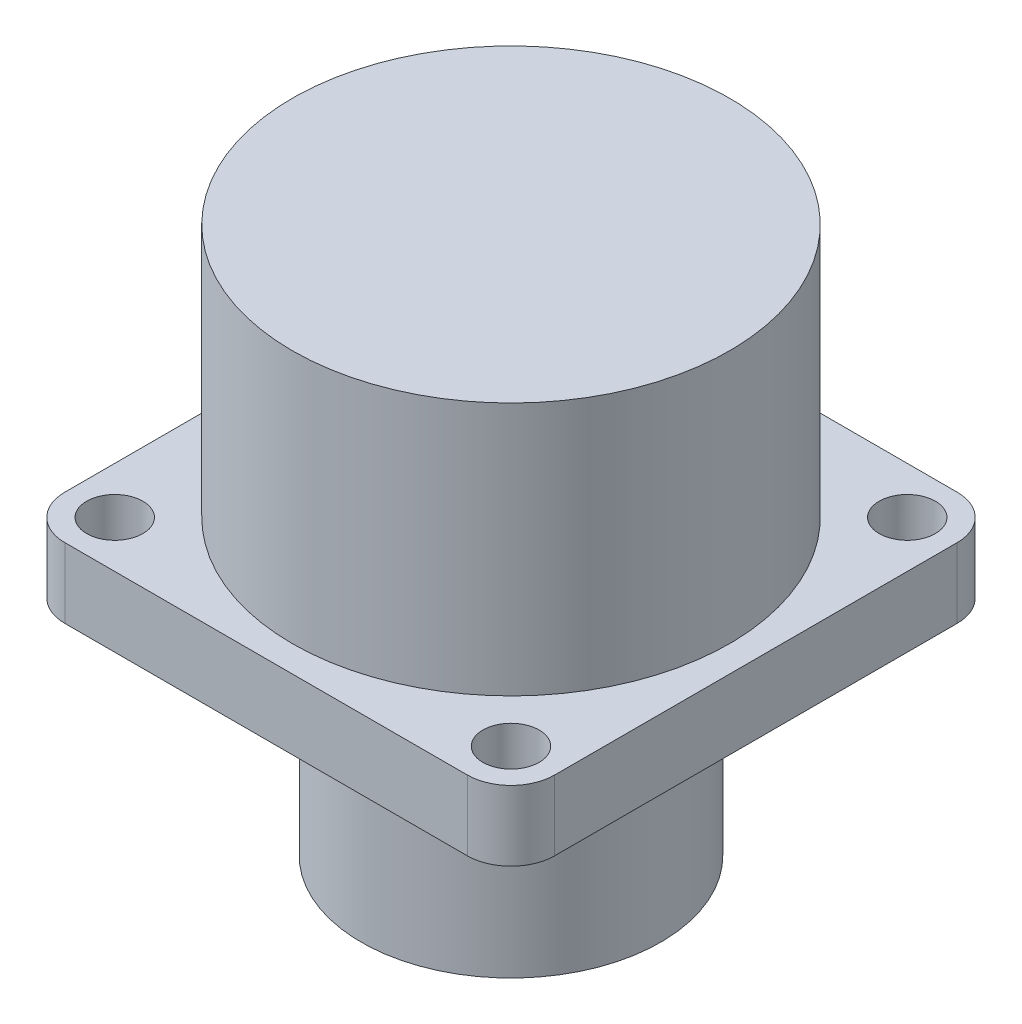
from build123d import *

# Parameters (mm, degrees)
SKETCH1_W                 = 28.448
SKETCH1_H                 = 28.448
BOSS_EXTRUDE1_DEPTH       = 4.064
SKETCH2_R                 = 12.7
BOSS_EXTRUDE2_DEPTH       = 14.732
SKETCH3_R                 = 8.6995
BOSS_EXTRUDE3_DEPTH       = 12.954
F_4_CLEARANCE_HOLE1_D     = 3.2639
F_4_CLEARANCE_HOLE1_DEPTH = 7.62
F_4_CLEARANCE_HOLE1_TIP   = 0.980574487
FILLET1_R                 = 2.54


with BuildPart() as part:
    # Sketch1 → Boss-Extrude1 (new body)
    with BuildSketch(Plane(origin=(0, 0, 0), x_dir=(1, 0, 0), z_dir=(0, 1, 0))):
        Rectangle(SKETCH1_W, SKETCH1_H)
    extrude(amount=BOSS_EXTRUDE1_DEPTH)

    # Sketch2 → Boss-Extrude2 (add)
    with BuildSketch(Plane(origin=(0, 4.064, 0), x_dir=(1, 0, 0), z_dir=(0, 1, 0))):
        Circle(SKETCH2_R)
    extrude(amount=BOSS_EXTRUDE2_DEPTH)

    # Sketch3 → Boss-Extrude3 (add)
    with BuildSketch(Plane.XZ):
        Circle(SKETCH3_R)
    extrude(amount=BOSS_EXTRUDE3_DEPTH)

    # 4 Clearance Hole1
    with Locations(Plane(origin=(0, 4.064, 0), x_dir=(1, 0, 0), z_dir=(0, 1, 0))):
        with Locations((-11.5062, -11.5062), (11.5062, 11.5062), (-11.5062, 11.5062), (11.5062, -11.5062)):
            Hole(F_4_CLEARANCE_HOLE1_D / 2, depth=F_4_CLEARANCE_HOLE1_DEPTH)
            with Locations((0, 0, -(F_4_CLEARANCE_HOLE1_DEPTH + F_4_CLEARANCE_HOLE1_TIP / 2))):  # 118° drill point
                Cone(0, F_4_CLEARANCE_HOLE1_D / 2, F_4_CLEARANCE_HOLE1_TIP, mode=Mode.SUBTRACT)

    # Fillet1
    fillet1_edges = [part.edges().sort_by_distance(p)[0] for p in [
        (14.224, 2.032, 14.224),
        (14.224, 2.032, -14.224),
        (-14.224, 2.032, 14.224),
        (-14.224, 2.032, -14.224),
    ]]
    fillet(fillet1_edges, radius=FILLET1_R)


solid = part.part
